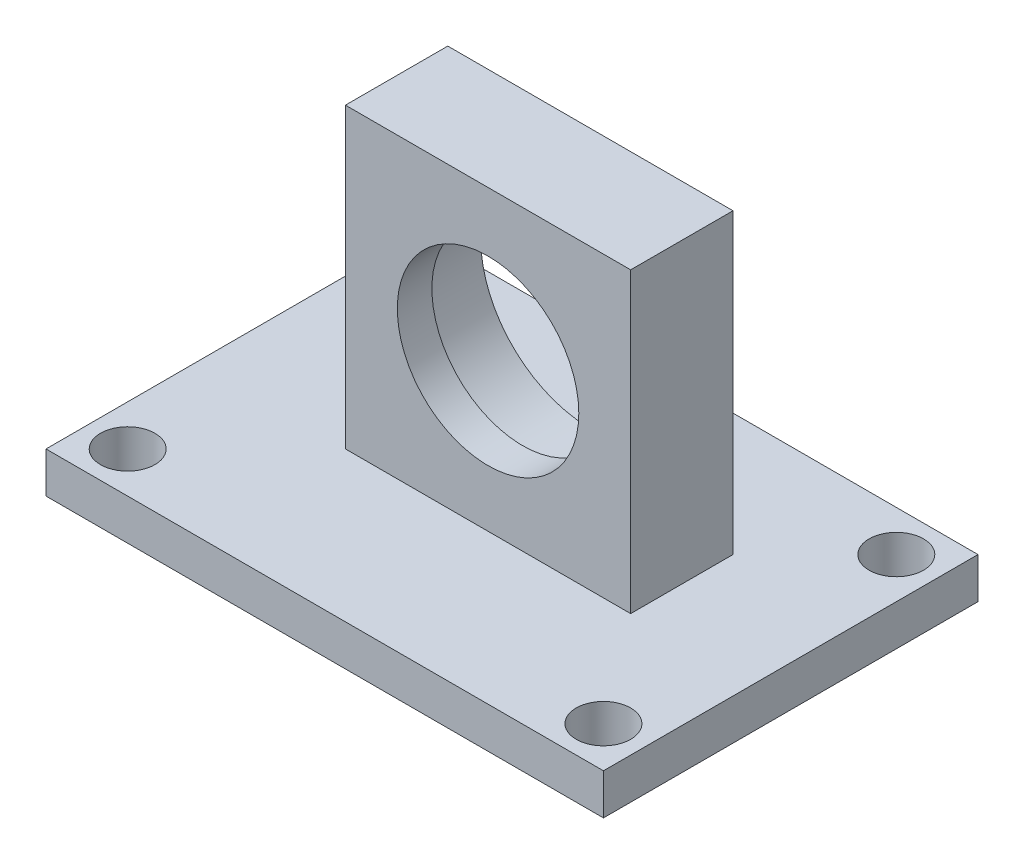
from build123d import *

# Parameters (mm, degrees)
SKETCH1_W           = 40.954999878
SKETCH1_H           = 27.518000082
BOSS_EXTRUDE1_DEPTH = 2.999994
SKETCH3_W           = 20.955
SKETCH3_H           = 7.5184
BOSS_EXTRUDE2_DEPTH = 21.874999989
SKETCH4_R           = 1.999996
CUT_EXTRUDE1_DEPTH  = 3.999994
SKETCH5_R           = 6.6675
CUT_EXTRUDE2_DEPTH  = 2.54
SKETCH6_R           = 8.0645
CUT_EXTRUDE3_DEPTH  = 4.9784


with BuildPart() as part:
    # Sketch1 → Boss-Extrude1 (new body)
    with BuildSketch(Plane(origin=(0, 0, 0), x_dir=(1, 0, 0), z_dir=(0, 1, 0))):
        with Locations((20.477499939, 13.759000041)):
            Rectangle(SKETCH1_W, SKETCH1_H)
    extrude(amount=-BOSS_EXTRUDE1_DEPTH)

    # Sketch3 → Boss-Extrude2 (add)
    with BuildSketch(Plane(origin=(0, 0, 0), x_dir=(1, 0, 0), z_dir=(0, 1, 0))):
        with Locations((21.4775034, 14.7592034)):
            Rectangle(SKETCH3_W, SKETCH3_H)
    extrude(amount=BOSS_EXTRUDE2_DEPTH)

    # Sketch4 → Cut-Extrude1 (cut, through all)
    with BuildSketch(Plane(origin=(0, 0, 0), x_dir=(1, 0, 0), z_dir=(0, 1, 0))):
        with Locations((2.999994, 24.518006082)):
            Circle(SKETCH4_R)
        with Locations((2.999994, 2.999994)):
            Circle(SKETCH4_R)
        with Locations((37.955005756, 2.999994)):
            Circle(SKETCH4_R)
        with Locations((37.955005756, 24.518006082)):
            Circle(SKETCH4_R)
    extrude(amount=-CUT_EXTRUDE1_DEPTH, mode=Mode.SUBTRACT)

    # Sketch5 → Cut-Extrude2 (cut)
    with BuildSketch(Plane.XY.offset(-11.0000034)):
        with Locations((21.4775034, 10.843006)):
            Circle(SKETCH5_R)
    extrude(amount=-CUT_EXTRUDE2_DEPTH, mode=Mode.SUBTRACT)

    # Sketch6 → Cut-Extrude3 (cut)
    with BuildSketch(Plane(origin=(0, 0, -18.5184034), x_dir=(-1, 0, 0), z_dir=(0, 0, -1))):
        with Locations((-21.4775034, 10.843006)):
            Circle(SKETCH6_R)
    extrude(amount=-CUT_EXTRUDE3_DEPTH, mode=Mode.SUBTRACT)


solid = part.part
